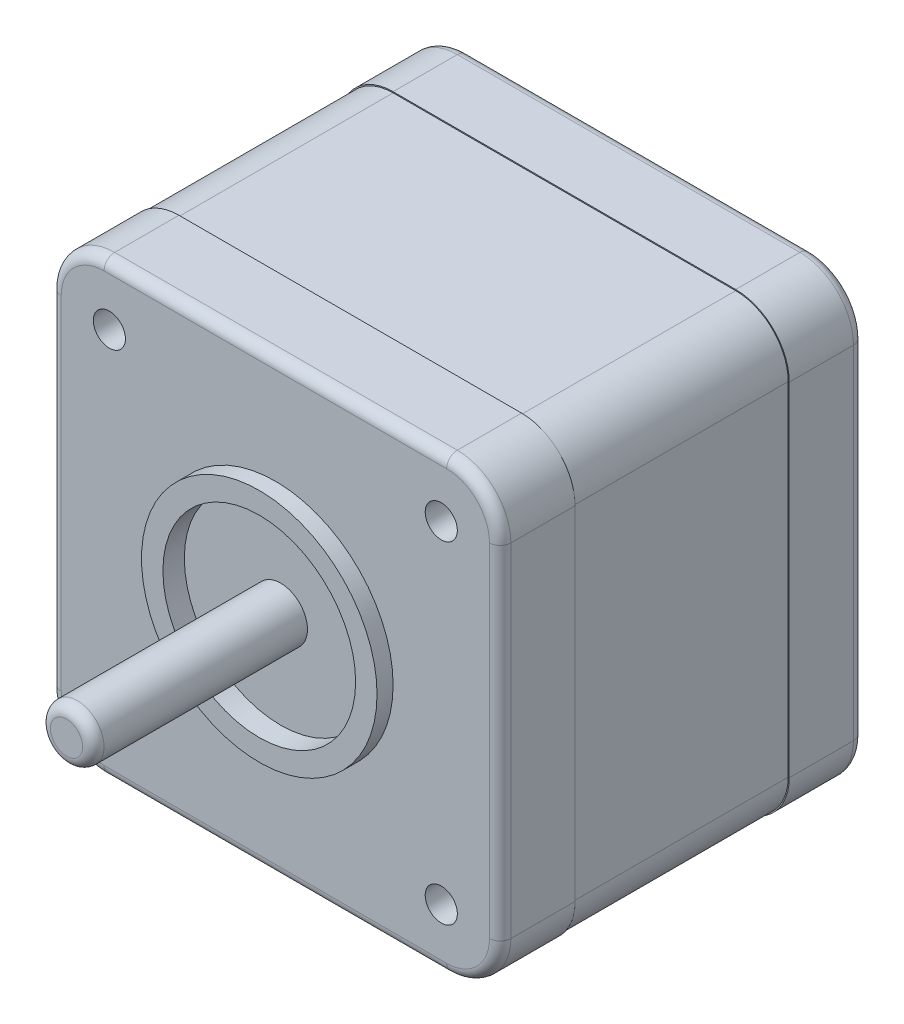
from build123d import *

# Parameters (mm, degrees)
BOSS_EXTRUDE1_DEPTH = 34
SKETCH4_R           = 11
BOSS_EXTRUDE2_DEPTH = 1.5
SKETCH5_W           = 15
SKETCH5_H           = 6
BOSS_EXTRUDE3_DEPTH = 6
SKETCH6_R           = 9
CUT_EXTRUDE1_DEPTH  = 2
SKETCH7_R           = 2.5
BOSS_EXTRUDE4_DEPTH = 20
CUT_EXTRUDE3_DEPTH  = 20
FILLET1_R           = 1
FILLET2_R           = 1
SKETCH9_R           = 1.5
CUT_EXTRUDE4_DEPTH  = 20


with BuildPart() as part:
    # Sketch2 → Boss-Extrude1 (new body)
    with BuildSketch(Plane.XY):
        with BuildLine():
            Line((-16, -21), (16, -21))
            ThreePointArc((16, -21), (19.535533906, -19.535533906), (21, -16))
            Line((21, -16), (21, 16))
            ThreePointArc((21, 16), (19.535533906, 19.535533906), (16, 21))
            Line((16, 21), (-16, 21))
            ThreePointArc((-16, 21), (-19.535533906, 19.535533906), (-21, 16))
            Line((-21, 16), (-21, -16))
            ThreePointArc((-21, -16), (-19.535533906, -19.535533906), (-16, -21))
        make_face()
    extrude(amount=BOSS_EXTRUDE1_DEPTH)

    # Sketch4 → Boss-Extrude2 (add)
    with BuildSketch(Plane.XY.offset(34)):
        Circle(SKETCH4_R)
    extrude(amount=BOSS_EXTRUDE2_DEPTH)

    # Sketch5 → Boss-Extrude3 (add)
    with BuildSketch(Plane.XZ.offset(21)):
        with Locations((0, 7)):
            Rectangle(SKETCH5_W, SKETCH5_H)
    extrude(amount=BOSS_EXTRUDE3_DEPTH)

    # Sketch6 → Cut-Extrude1 (cut)
    with BuildSketch(Plane.XY.offset(35.5)):
        Circle(SKETCH6_R)
    extrude(amount=-CUT_EXTRUDE1_DEPTH, mode=Mode.SUBTRACT)

    # Sketch7 → Boss-Extrude4 (add)
    with BuildSketch(Plane.XY.offset(33.5)):
        Circle(SKETCH7_R)
    extrude(amount=BOSS_EXTRUDE4_DEPTH)

    # Sketch8 → Cut-Extrude3 (cut)
    with BuildSketch(Plane.XY.offset(27)):
        with BuildLine():
            Line((16, 21), (-16, 21))
            ThreePointArc((-16, 21), (-19.535533906, 19.535533906), (-21, 16))
            Line((-21, 16), (-21, -16))
            ThreePointArc((-21, -16), (-19.535533906, -19.535533906), (-16, -21))
            Line((-16, -21), (16, -21))
            ThreePointArc((16, -21), (19.535533906, -19.535533906), (21, -16))
            Line((21, -16), (21, 16))
            ThreePointArc((21, 16), (19.535533906, 19.535533906), (16, 21))
        make_face()
        with BuildLine():
            Line((16, 20.9), (-16, 20.9))
            ThreePointArc((-16, 20.9), (-19.464823228, 19.464823228), (-20.9, 16))
            Line((-20.9, 16), (-20.9, -16))
            ThreePointArc((-20.9, -16), (-19.464823228, -19.464823228), (-16, -20.9))
            Line((-16, -20.9), (16, -20.9))
            ThreePointArc((16, -20.9), (19.464823228, -19.464823228), (20.9, -16))
            Line((20.9, -16), (20.9, 16))
            ThreePointArc((20.9, 16), (19.464823228, 19.464823228), (16, 20.9))
        make_face(mode=Mode.SUBTRACT)
    extrude(amount=-CUT_EXTRUDE3_DEPTH, mode=Mode.SUBTRACT)

    # Fillet1
    fillet1_edges = [part.edges().sort_by_distance(p)[0] for p in [
        (-21, 0, 0),
        (-19.535533906, 19.535533906, 0),
        (0, 21, 0),
        (19.535533906, 19.535533906, 0),
        (-19.535533906, 19.535533906, 34),
        (-21, 0, 34),
        (-19.535533906, -19.535533906, 34),
        (0, -21, 34),
        (19.535533906, -19.535533906, 34),
        (21, 0, 34),
        (19.535533906, 19.535533906, 34),
        (21, 0, 0),
        (0, 21, 34),
        (19.535533906, -19.535533906, 0),
        (0, -21, 0),
        (-19.535533906, -19.535533906, 0),
    ]]
    fillet(fillet1_edges, radius=FILLET1_R)

    # Fillet2
    fillet2_edges = [part.edges().sort_by_distance(p)[0] for p in [
        (-2.5, 0, 53.5),
    ]]
    fillet(fillet2_edges, radius=FILLET2_R)

    # Sketch9 → Cut-Extrude4 (cut)
    with BuildSketch(Plane.XY.offset(34)):
        with Locations((15.5, 15.5)):
            Circle(SKETCH9_R)
        with Locations((15.5, -15.5)):
            Circle(SKETCH9_R)
        with Locations((-15.5, -15.5)):
            Circle(SKETCH9_R)
        with Locations((-15.5, 15.5)):
            Circle(SKETCH9_R)
    extrude(amount=-CUT_EXTRUDE4_DEPTH, mode=Mode.SUBTRACT)


solid = part.part
